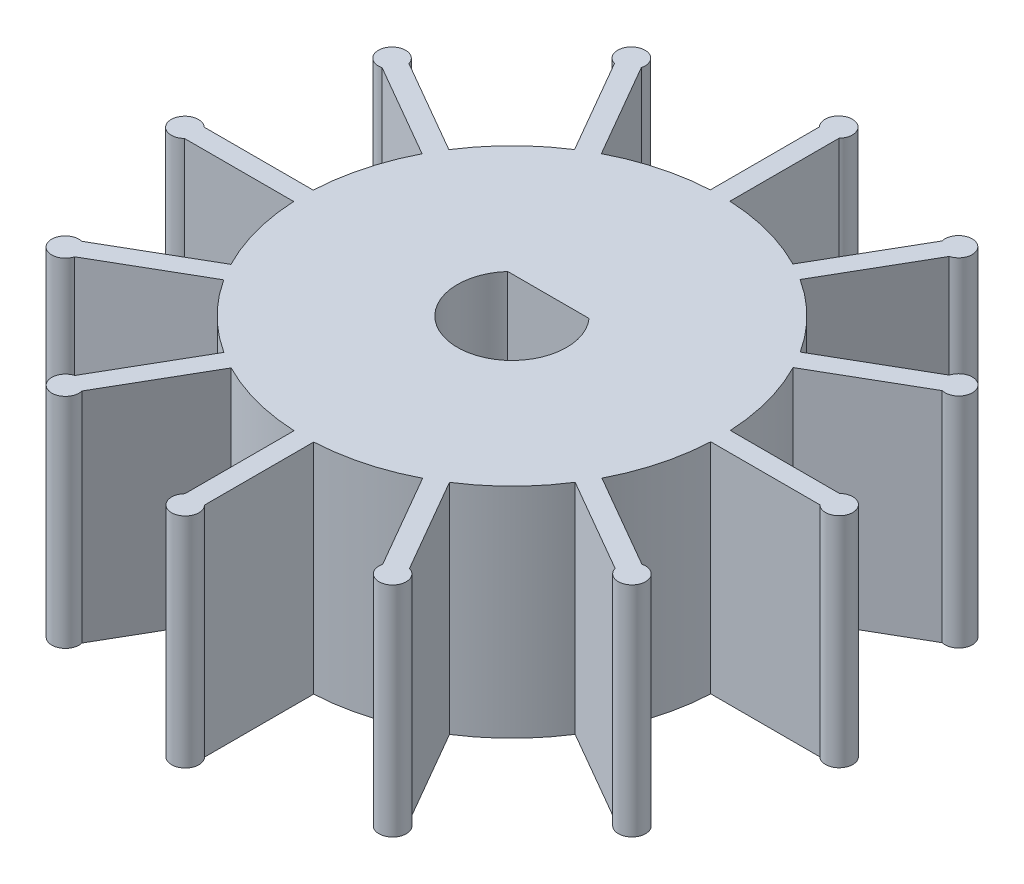
from build123d import *

# Parameters (mm, degrees)
BOSS_EXTRUDE1_DEPTH = 12
CUT_EXTRUDE1_DEPTH  = 13


with BuildPart() as part:
    # Sketch1 → Boss-Extrude1 (new body)
    with BuildSketch(Plane(origin=(0, 0, 0), x_dir=(1, 0, 0), z_dir=(0, 1, 0))):
        with BuildLine():
            Line((-0.551192068, 17.450239661), (-0.551192068, 11.450239661))
            ThreePointArc((-0.551192068, 11.450239661), (-2.978402467, 11.069820222), (-5.268807469, 10.180936541))
            Line((-5.268807469, 10.180936541), (-8.268250593, 15.376124426))
            ThreePointArc((-8.268250593, 15.376124426), (-9.370925272, 16.20727377), (-9.202466164, 14.836754815))
            Line((-9.202466164, 14.836754815), (-6.202466164, 9.640602392))
            ThreePointArc((-6.202466164, 9.640602392), (-8.11428231, 8.097544294), (-9.653389387, 6.182545944))
            Line((-9.653389387, 6.182545944), (-14.848577272, 9.181989068))
            ThreePointArc((-14.848577272, 9.181989068), (-16.219096227, 9.350448175), (-15.387946883, 8.247773497))
            Line((-15.387946883, 8.247773497), (-10.19179446, 5.247773497))
            ThreePointArc((-10.19179446, 5.247773497), (-11.075946761, 2.955537911), (-11.451353414, 0.527547154))
            Line((-11.451353414, 0.527547154), (-17.450239661, 0.527547154))
            ThreePointArc((-17.450239661, 0.527547154), (-18.721373447, -0.011822457), (-17.450239661, -0.551192068))
            Line((-17.450239661, -0.551192068), (-11.450239661, -0.551192068))
            ThreePointArc((-11.450239661, -0.551192068), (-11.069820222, -2.978402467), (-10.180936541, -5.268807469))
            Line((-10.180936541, -5.268807469), (-15.376124426, -8.268250593))
            ThreePointArc((-15.376124426, -8.268250593), (-16.20727377, -9.370925272), (-14.836754815, -9.202466164))
            Line((-14.836754815, -9.202466164), (-9.640602392, -6.202466164))
            ThreePointArc((-9.640602392, -6.202466164), (-8.097544294, -8.11428231), (-6.182545944, -9.653389387))
            Line((-6.182545944, -9.653389387), (-9.181989068, -14.848577272))
            ThreePointArc((-9.181989068, -14.848577272), (-9.350448175, -16.219096227), (-8.247773497, -15.387946883))
            Line((-8.247773497, -15.387946883), (-5.247773497, -10.19179446))
            ThreePointArc((-5.247773497, -10.19179446), (-2.955537911, -11.075946761), (-0.527547154, -11.451353414))
            Line((-0.527547154, -11.451353414), (-0.527547154, -17.450239661))
            ThreePointArc((-0.527547154, -17.450239661), (0.011822457, -18.721373447), (0.551192068, -17.450239661))
            Line((0.551192068, -17.450239661), (0.551192068, -11.450239661))
            ThreePointArc((0.551192068, -11.450239661), (2.978402467, -11.069820222), (5.268807469, -10.180936541))
            Line((5.268807469, -10.180936541), (8.268250593, -15.376124426))
            ThreePointArc((8.268250593, -15.376124426), (9.370925272, -16.20727377), (9.202466164, -14.836754815))
            Line((9.202466164, -14.836754815), (6.202466164, -9.640602392))
            ThreePointArc((6.202466164, -9.640602392), (8.11428231, -8.097544294), (9.653389387, -6.182545944))
            Line((9.653389387, -6.182545944), (14.848577272, -9.181989068))
            ThreePointArc((14.848577272, -9.181989068), (16.219096227, -9.350448175), (15.387946883, -8.247773497))
            Line((15.387946883, -8.247773497), (10.19179446, -5.247773497))
            ThreePointArc((10.19179446, -5.247773497), (11.075946761, -2.955537911), (11.451353414, -0.527547154))
            Line((11.451353414, -0.527547154), (17.450239661, -0.527547154))
            ThreePointArc((17.450239661, -0.527547154), (18.721373447, 0.011822457), (17.450239661, 0.551192068))
            Line((17.450239661, 0.551192068), (11.450239661, 0.551192068))
            ThreePointArc((11.450239661, 0.551192068), (11.069820222, 2.978402467), (10.180936541, 5.268807469))
            Line((10.180936541, 5.268807469), (15.376124426, 8.268250593))
            ThreePointArc((15.376124426, 8.268250593), (16.20727377, 9.370925272), (14.836754815, 9.202466164))
            Line((14.836754815, 9.202466164), (9.640602392, 6.202466164))
            ThreePointArc((9.640602392, 6.202466164), (8.097544294, 8.11428231), (6.182545944, 9.653389387))
            Line((6.182545944, 9.653389387), (9.181989068, 14.848577272))
            ThreePointArc((9.181989068, 14.848577272), (9.350448175, 16.219096227), (8.247773497, 15.387946883))
            Line((8.247773497, 15.387946883), (5.247773497, 10.19179446))
            ThreePointArc((5.247773497, 10.19179446), (2.955537911, 11.075946761), (0.527547154, 11.451353414))
            Line((0.527547154, 11.451353414), (0.527547154, 17.450239661))
            ThreePointArc((0.527547154, 17.450239661), (-0.011822457, 18.721373447), (-0.551192068, 17.450239661))
        make_face()
    extrude(amount=BOSS_EXTRUDE1_DEPTH)

    # Sketch2 → Cut-Extrude1 (cut, through all)
    with BuildSketch(Plane(origin=(0, 12, 0), x_dir=(1, 0, 0), z_dir=(0, 1, 0))):
        with BuildLine():
            Line((-2.236067977, 2), (2.236067977, 2))
            ThreePointArc((2.236067977, 2), (0, -3), (-2.236067977, 2))
        make_face()
    extrude(amount=-CUT_EXTRUDE1_DEPTH, mode=Mode.SUBTRACT)


solid = part.part
